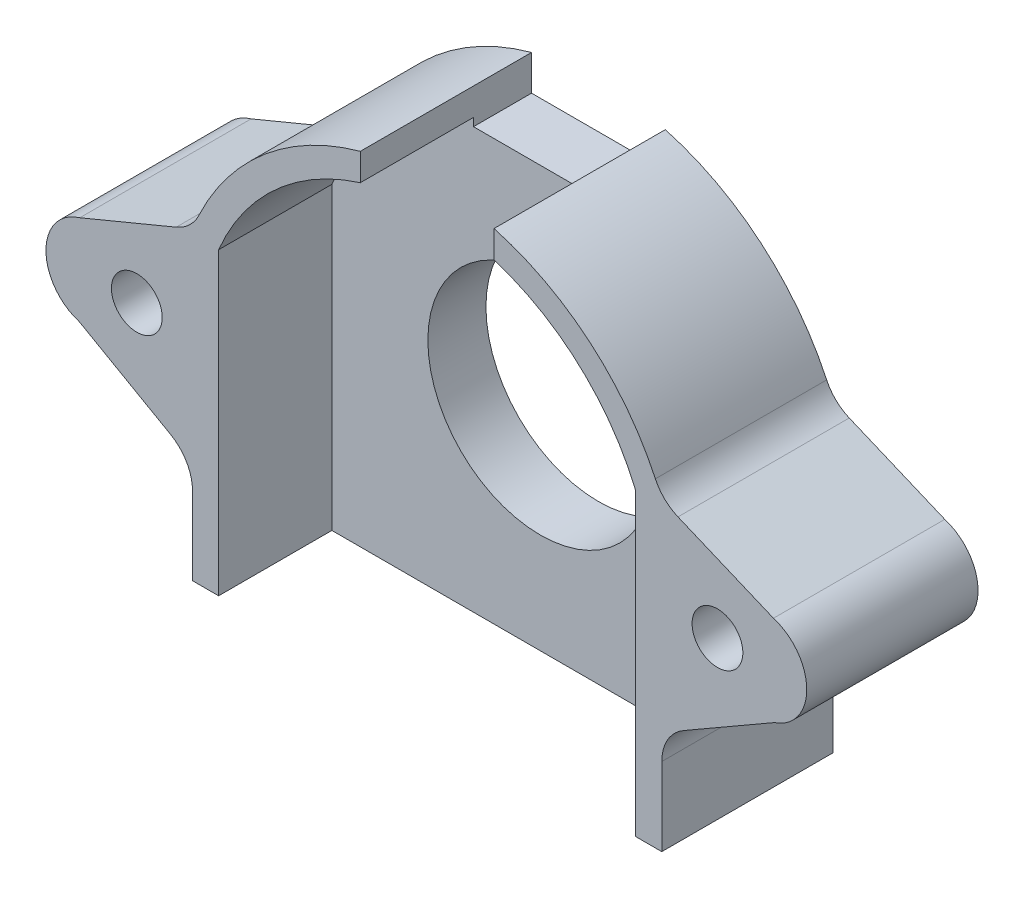
from build123d import *

# Parameters (mm, degrees)
BOSS_EXTRUDE1_DEPTH = 4
BOSS_EXTRUDE2_DEPTH = 7.8
SKETCH4_W           = 33.781239108
SKETCH4_H           = 10.810531084
CUT_EXTRUDE1_DEPTH  = 28.88035773
SKETCH6_R           = 1.75
BOSS_EXTRUDE3_DEPTH = 3
FILLET1_R           = 3
CUT_EXTRUDE2_REACH  = 35.305
SKETCH7_R           = 7.75
SKETCH8_R           = 1.75
BOSS_EXTRUDE4_DEPTH = 8.8
BOSS_EXTRUDE5_DEPTH = 2


with BuildPart() as part:
    # Sketch2 → Boss-Extrude1 (new body)
    with BuildSketch(Plane.XY):
        with BuildLine():
            Line((3.481334242, 16.311673717), (-3.481334242, 16.311673717))
            Line((-3.481334242, 16.311673717), (-4.292170887, 16.824998456))
            ThreePointArc((-4.292170887, 16.824998456), (-11.492625639, 13.016253681), (-16.163850494, 6.342967853))
            Line((-16.163850494, 6.342967853), (-16.163850494, -14.391495343))
            Line((-16.163850494, -14.391495343), (-14.353897969, -14.640433541))
            Line((-14.353897969, -14.640433541), (-10.527602773, -17.523753782))
            Line((-10.527602773, -17.523753782), (-10.527602773, -19.404011272))
            Line((-10.527602773, -19.404011272), (-5.007128349, -19.404011272))
            Line((-5.007128349, -19.404011272), (-5.007128349, -17.507596758))
            Line((-5.007128349, -17.507596758), (5, -17.507596758))
            Line((5, -17.507596758), (5, -19.411447251))
            Line((5, -19.411447251), (10.467237067, -19.411447251))
            Line((10.467237067, -19.411447251), (10.467237067, -17.567178369))
            Line((10.467237067, -17.567178369), (14.33922382, -14.64942707))
            Line((14.33922382, -14.64942707), (16.163850494, -14.424396197))
            Line((16.163850494, -14.424396197), (16.163850494, 6.342967853))
            ThreePointArc((16.163850494, 6.342967853), (11.492625639, 13.016253681), (4.292170887, 16.824998456))
            Line((4.292170887, 16.824998456), (3.481334242, 16.311673717))
        make_face()
    extrude(amount=BOSS_EXTRUDE1_DEPTH)

    # Sketch3 → Boss-Extrude2 (add)
    with BuildSketch(Plane.XY.offset(4)):
        with BuildLine():
            Line((4.292170887, 16.824998456), (3.481334242, 16.311673717))
            Line((3.481334242, 16.311673717), (-3.481334242, 16.311673717))
            Line((-3.481334242, 16.311673717), (-4.292170887, 16.824998456))
            ThreePointArc((-4.292170887, 16.824998456), (-11.492625639, 13.016253681), (-16.163850494, 6.342967853))
            Line((-16.163850494, 6.342967853), (-16.163850494, -14.391495343))
            Line((-16.163850494, -14.391495343), (-14.353897969, -14.640433541))
            Line((-14.353897969, -14.640433541), (-10.527602773, -17.523753782))
            Line((-10.527602773, -17.523753782), (-10.527602773, -19.404011272))
            Line((-10.527602773, -19.404011272), (-5.007128349, -19.404011272))
            Line((-5.007128349, -19.404011272), (-5.007128349, -17.507596758))
            Line((-5.007128349, -17.507596758), (5, -17.507596758))
            Line((5, -17.507596758), (5, -19.411447251))
            Line((5, -19.411447251), (10.467237067, -19.411447251))
            Line((10.467237067, -19.411447251), (10.467237067, -17.567178369))
            Line((10.467237067, -17.567178369), (14.33922382, -14.64942707))
            Line((14.33922382, -14.64942707), (16.163850494, -14.424396197))
            Line((16.163850494, -14.424396197), (16.163850494, 6.342967853))
            ThreePointArc((16.163850494, 6.342967853), (11.492625639, 13.016253681), (4.292170887, 16.824998456))
        make_face()
        with BuildLine():
            Line((4.003211271, 14.511673717), (-4.003211271, 14.511673717))
            Line((-4.003211271, 14.511673717), (-4.577751285, 14.875403704))
            ThreePointArc((-4.577751285, 14.875403704), (-10.460467666, 11.524411412), (-14.363850494, 5.992765737))
            Line((-14.363850494, 5.992765737), (-14.363850494, -12.822119288))
            Line((-14.363850494, -12.822119288), (-13.644664568, -12.921035058))
            Line((-13.644664568, -12.921035058), (-8.727602773, -16.626306888))
            Line((-8.727602773, -16.626306888), (-8.727602773, -17.604011272))
            Line((-8.727602773, -17.604011272), (-6.807128349, -17.604011272))
            Line((-6.807128349, -17.604011272), (-6.807128349, -15.707596758))
            Line((-6.807128349, -15.707596758), (6.8, -15.707596758))
            Line((6.8, -15.707596758), (6.8, -17.611447251))
            Line((6.8, -17.611447251), (8.667237067, -17.611447251))
            Line((8.667237067, -17.611447251), (8.667237067, -16.669731475))
            Line((8.667237067, -16.669731475), (13.640731753, -12.921934411))
            Line((13.640731753, -12.921934411), (14.363850494, -12.832752309))
            Line((14.363850494, -12.832752309), (14.363850494, 5.992765737))
            ThreePointArc((14.363850494, 5.992765737), (10.460467666, 11.524411412), (4.577751285, 14.875403704))
            Line((4.577751285, 14.875403704), (4.003211271, 14.511673717))
        make_face(mode=Mode.SUBTRACT)
    extrude(amount=BOSS_EXTRUDE2_DEPTH)

    # Sketch4 → Cut-Extrude1 (cut, through all)
    with BuildSketch(Plane(origin=(0, 0, 0), x_dir=(-1, 0, 0), z_dir=(0, 0, -1))):
        Polygon((-4.606626741, 14.656974178), (-4.606626741, 16.741633553), (-2.485703279, 20.488617531), (2.721605339, 20.671050509), (4.606626741, 16.741633553), (4.606626741, 14.656974178), (4.606626741, 14.311673717), (-4.606626741, 14.311673717), align=None)
        with Locations((0.72676906, -18.06116853)):
            Rectangle(SKETCH4_W, SKETCH4_H)
    extrude(amount=-CUT_EXTRUDE1_DEPTH, mode=Mode.SUBTRACT)

    # Sketch6 → Boss-Extrude3 (add)
    with BuildSketch(Plane.XY.offset(11.8)):
        with BuildLine():
            Line((-16.163850494, -7.542701658), (-16.163850494, 6.342967853))
            Line((-16.163850494, 6.342967853), (-23.929756214, 3.11778647))
            ThreePointArc((-23.929756214, 3.11778647), (-26.262186338, 0.009769983), (-23.948484604, -3.11221353))
            Line((-23.948484604, -3.11221353), (-16.163850494, -7.542701658))
        make_face()
        with Locations((-20, 0)):
            Circle(SKETCH6_R, mode=Mode.SUBTRACT)
        with BuildLine():
            Line((16.163850494, -7.542701658), (16.163850494, 6.342967853))
            Line((16.163850494, 6.342967853), (23.859195057, 3.11778647))
            ThreePointArc((23.859195057, 3.11778647), (26.152039317, 0.046872999), (23.925870502, -3.072712992))
            Line((23.925870502, -3.072712992), (16.163850494, -7.542701658))
        make_face()
        with Locations((20, 0)):
            Circle(SKETCH6_R, mode=Mode.SUBTRACT)
    extrude(amount=-BOSS_EXTRUDE3_DEPTH)

    # Fillet1
    fillet1_edges = [part.edges().sort_by_distance(p)[0] for p in [
        (16.163850494, -7.542701658, 10.3),
        (-16.163850494, -7.542701658, 10.3),
        (16.163850494, 6.342967853, 10.3),
        (-16.163850494, 6.342967853, 10.3),
    ]]
    fillet(fillet1_edges, radius=FILLET1_R)

    # Sketch7 → Cut-Extrude2 (cut, up to next)
    with BuildSketch(Plane(origin=(0, 0, 0), x_dir=(-1, 0, 0), z_dir=(0, 0, -1)), mode=Mode.PRIVATE) as cut_extrude2_sk1:
        Circle(SKETCH7_R)
    cut_extrude2_tool1 = extrude(cut_extrude2_sk1.sketch, amount=-CUT_EXTRUDE2_REACH, mode=Mode.PRIVATE) & part.part
    add(cut_extrude2_tool1.solids().sort_by_distance((0, 0, 0))[0], mode=Mode.SUBTRACT)

    # Sketch8 → Boss-Extrude4 (add)
    with BuildSketch(Plane(origin=(0, 0, 8.8), x_dir=(-1, 0, 0), z_dir=(0, 0, -1))):
        with BuildLine():
            Line((-17.279436212, 5.875416821), (-23.859195057, 3.11778647))
            ThreePointArc((-23.859195057, 3.11778647), (-26.152039317, 0.046872999), (-23.925870502, -3.072712992))
            Line((-23.925870502, -3.072712992), (-17.666718993, -6.677230408))
            ThreePointArc((-17.666718993, -6.677230408), (-16.566602479, -7.775527074), (-16.163850494, -9.276960639))
            Line((-16.163850494, -9.276960639), (-16.163850494, 6.342967853))
            ThreePointArc((-16.163850494, 6.342967853), (-15.951477639, 6.859567413), (-15.722599163, 7.369069108))
            ThreePointArc((-15.722599163, 7.369069108), (-16.362099709, 6.477448451), (-17.279436212, 5.875416821))
        make_face()
        with Locations(Location((-20, 0, 0), (0, 0, 180))):
            Circle(SKETCH8_R, mode=Mode.SUBTRACT)
        with BuildLine():
            Line((17.679948892, -6.679840815), (23.948484604, -3.11221353))
            ThreePointArc((23.948484604, -3.11221353), (26.262186338, 0.009769983), (23.929756214, 3.11778647))
            Line((23.929756214, 3.11778647), (17.285932986, 5.876966887))
            ThreePointArc((17.285932986, 5.876966887), (16.363441184, 6.479081897), (15.720481601, 7.373585437))
            ThreePointArc((15.720481601, 7.373585437), (15.9504922, 6.861858534), (16.163850494, 6.342967853))
            Line((16.163850494, 6.342967853), (16.163850494, -9.287145177))
            ThreePointArc((16.163850494, -9.287145177), (16.570425653, -7.779117459), (17.679948892, -6.679840815))
        make_face()
        with Locations(Location((20, 0, 0), (0, 0, 180))):
            Circle(SKETCH8_R, mode=Mode.SUBTRACT)
    extrude(amount=BOSS_EXTRUDE4_DEPTH)

    # Sketch9 → Boss-Extrude5 (add)
    with BuildSketch(Plane.XZ.offset(12.655902988)):
        Polygon((-16.163850494, 0), (16.163850494, 0), (16.163850494, 11.8), (14.363850494, 11.8), (14.363850494, 4), (-14.363850494, 4), (-14.363850494, 11.8), (-16.163850494, 11.8), align=None)
    extrude(amount=BOSS_EXTRUDE5_DEPTH)


solid = part.part
